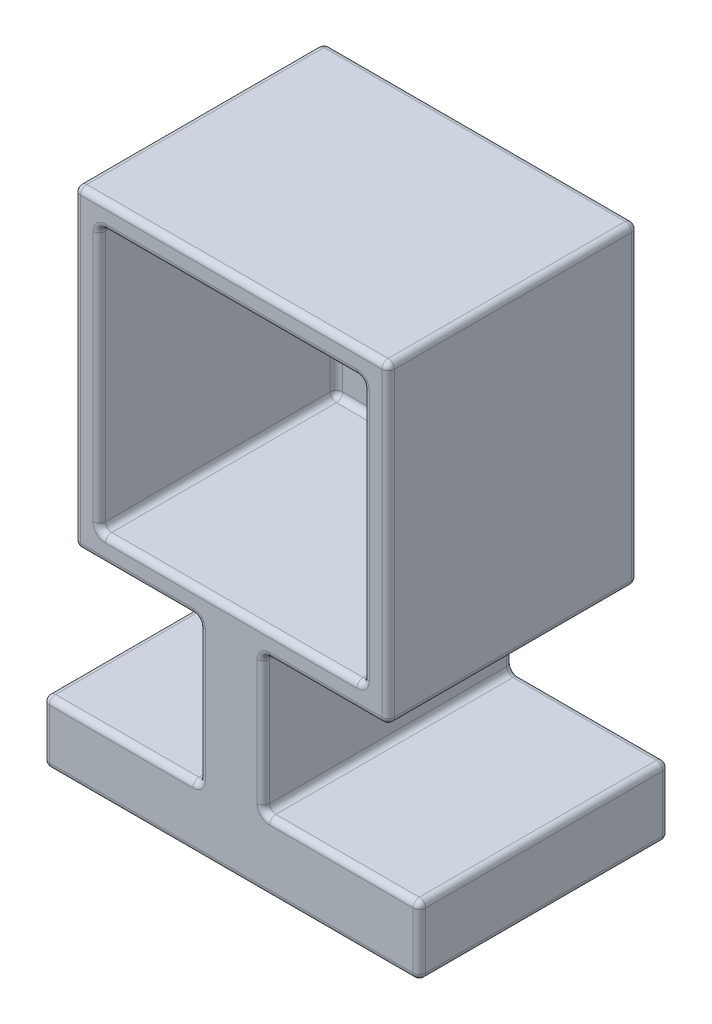
from build123d import *

# Parameters (mm, degrees)
SKETCH1_W               = 42.3
SKETCH1_H               = 42.3
BOSS_EXTRUDE2_DEPTH     = 2
SKETCH1_5_W             = 42.3
SKETCH1_5_H             = 42.3
BOSS_EXTRUDE3_DEPTH     = 40
SKETCH1_6_R             = 11
CUT_EXTRUDE2_DEPTH      = 2
CUT_EXTRUDE2_DEPTH_BACK = 1
FILLET1_R               = 1


with BuildPart() as part:
    # Sketch1 → Boss-Extrude2 (new body)
    with BuildSketch(Plane.XY):
        with Locations((21.15, 21.15)):
            Rectangle(SKETCH1_W, SKETCH1_H)
    extrude(amount=BOSS_EXTRUDE2_DEPTH)

    # Sketch1_5 → Boss-Extrude3 (add)
    with BuildSketch(Plane.XY):
        Polygon((46.3, 46.3), (-4, 46.3), (-4, -4), (16, -4), (16, -26.99133885), (-9, -26.99133885), (-9, -36.99133885), (51.3, -36.99133885), (51.3, -25.99133885), (26.3, -25.99133885), (26.3, -4), (46.3, -4), align=None)
        with Locations((21.15, 21.15)):
            Rectangle(SKETCH1_5_W, SKETCH1_5_H, mode=Mode.SUBTRACT)
    extrude(amount=BOSS_EXTRUDE3_DEPTH)

    # Sketch1_6 → Cut-Extrude2 (cut, two sides)
    with BuildSketch(Plane.XY) as cut_extrude2_sk:
        with Locations((21.15, 21.15)):
            Circle(SKETCH1_6_R)
    extrude(amount=CUT_EXTRUDE2_DEPTH, mode=Mode.SUBTRACT)
    extrude(cut_extrude2_sk.sketch, amount=-CUT_EXTRUDE2_DEPTH_BACK, mode=Mode.SUBTRACT)

    # Fillet1
    fillet1_edges = [part.edges().sort_by_distance(p)[0] for p in [
        (10.15, 21.15, 0),
        (21.15, 42.3, 2),
        (0, 21.15, 2),
        (21.15, 0, 2),
        (42.3, 21.15, 2),
        (21.15, 46.3, 40),
        (46.3, 46.3, 20),
        (0, 0, 21),
        (42.3, 0, 21),
        (21.15, 0, 40),
        (42.3, 42.3, 21),
        (42.3, 21.15, 40),
        (0, 42.3, 21),
        (-4, 21.15, 0),
        (-4, 46.3, 20),
        (46.3, 21.15, 40),
        (46.3, -4, 20),
        (46.3, 21.15, 0),
        (26.3, -14.995669425, 0),
        (21.15, 46.3, 0),
        (0, 21.15, 40),
        (21.15, 42.3, 40),
        (-4, 21.15, 40),
        (6, -4, 40),
        (16, -15.495669425, 40),
        (3.5, -26.99133885, 40),
        (-9, -31.99133885, 40),
        (21.15, -36.99133885, 40),
        (51.3, -31.49133885, 40),
        (38.8, -25.99133885, 40),
        (36.3, -4, 40),
        (26.3, -4, 20),
        (36.3, -4, 0),
        (-4, -4, 20),
        (6, -4, 0),
        (51.3, -31.49133885, 0),
        (51.3, -36.99133885, 20),
        (21.15, -36.99133885, 0),
        (-9, -36.99133885, 20),
        (-9, -31.99133885, 0),
        (-9, -26.99133885, 20),
        (3.5, -26.99133885, 0),
        (16, -26.99133885, 20),
        (38.8, -25.99133885, 0),
        (51.3, -25.99133885, 20),
        (26.3, -14.995669425, 40),
        (26.3, -25.99133885, 20),
        (16, -15.495669425, 0),
        (16, -4, 20),
    ]]
    fillet(fillet1_edges, radius=FILLET1_R)


solid = part.part
